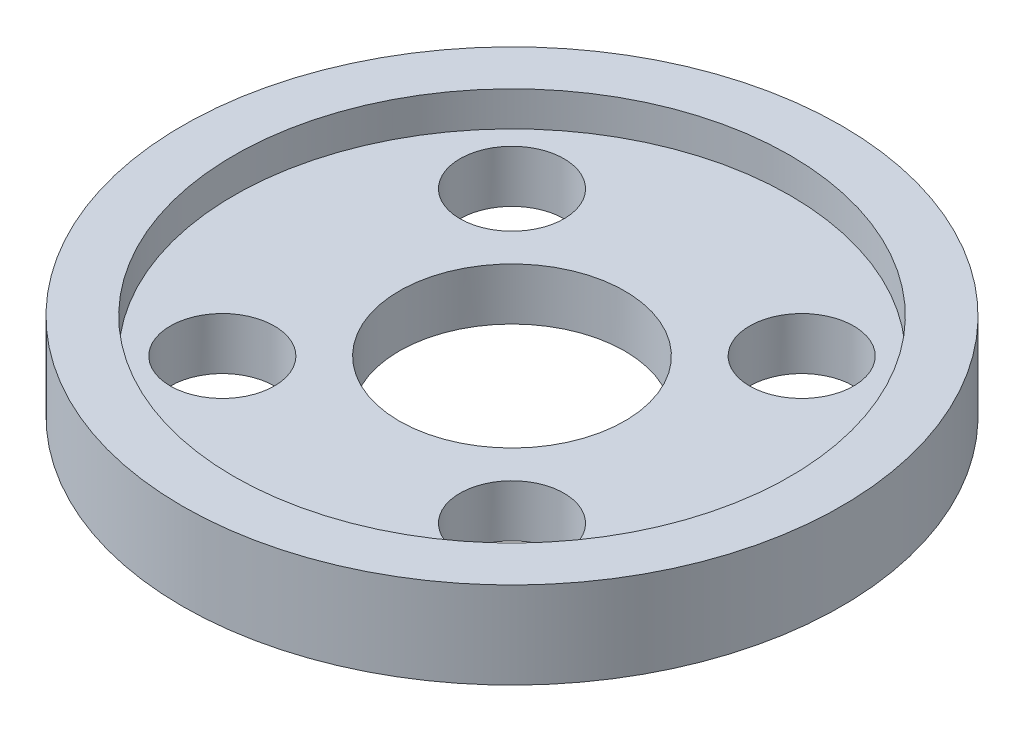
from build123d import *

# Parameters (mm, degrees)
SKETCH1_R           = 105
BOSS_EXTRUDE1_DEPTH = 40
SKETCH3_R           = 6.5
CUT_EXTRUDE2_DEPTH  = 40
SKETCH4_R           = 16.035
CUT_EXTRUDE3_DEPTH  = 5
SKETCH8_R           = 3
CUT_EXTRUDE6_DEPTH  = 44.5
SKETCH11_R          = 90
SKETCH11_R_2        = 26.035
CUT_EXTRUDE8_DEPTH  = 10
BOSS_EXTRUDE2_START = -3
SKETCH12_R          = 108
SKETCH12_R_2        = 105
BOSS_EXTRUDE2_DEPTH = 3
SKETCH13_R          = 108
SKETCH13_R_2        = 19
CUT_EXTRUDE9_DEPTH  = 158.886034848
SKETCH14_R          = 27.444507403
CUT_EXTRUDE10_DEPTH = 32
SKETCH15_R          = 19
CUT_EXTRUDE11_DEPTH = 3


with BuildPart() as part:
    # Sketch1 → Boss-Extrude1 (new body)
    with BuildSketch(Plane(origin=(0, 0, 0), x_dir=(1, 0, 0), z_dir=(0, 1, 0))):
        Circle(SKETCH1_R)
    extrude(amount=BOSS_EXTRUDE1_DEPTH)

    # Sketch3 → Cut-Extrude2 (cut)
    with BuildSketch(Plane(origin=(0, 40, 0), x_dir=(1, 0, 0), z_dir=(0, 1, 0))):
        Circle(SKETCH3_R)
    extrude(amount=-CUT_EXTRUDE2_DEPTH, mode=Mode.SUBTRACT)

    # Sketch4 → Cut-Extrude3 (cut)
    with BuildSketch(Plane(origin=(0, 40, 0), x_dir=(1, 0, 0), z_dir=(0, 1, 0))):
        Circle(SKETCH4_R)
    extrude(amount=-CUT_EXTRUDE3_DEPTH, mode=Mode.SUBTRACT)

    # Sketch8 → Cut-Extrude6 (cut)
    with BuildSketch(Plane(origin=(0, 35, 0), x_dir=(1, 0, 0), z_dir=(0, 1, 0))):
        with Locations((-8.35, 8.35)):
            Circle(SKETCH8_R)
        with Locations((8.35, 8.35)):
            Circle(SKETCH8_R)
        with Locations((8.35, -8.35)):
            Circle(SKETCH8_R)
        with Locations((-8.35, -8.35)):
            Circle(SKETCH8_R)
    extrude(amount=-CUT_EXTRUDE6_DEPTH, mode=Mode.SUBTRACT)

    # Sketch11 → Cut-Extrude8 (cut)
    with BuildSketch(Plane(origin=(0, 40, 0), x_dir=(1, 0, 0), z_dir=(0, 1, 0))):
        Circle(SKETCH11_R)
        Circle(SKETCH11_R_2, mode=Mode.SUBTRACT)
    extrude(amount=-CUT_EXTRUDE8_DEPTH, mode=Mode.SUBTRACT)

    # Sketch12 → Boss-Extrude2 (add)
    with BuildSketch(Plane(origin=(0, 40, 0), x_dir=(1, 0, 0), z_dir=(0, 1, 0)).offset(BOSS_EXTRUDE2_START)):
        Circle(SKETCH12_R)
        Circle(SKETCH12_R_2, mode=Mode.SUBTRACT)
    boss_extrude2 = extrude(amount=BOSS_EXTRUDE2_DEPTH)

    # Mirror1: Boss-Extrude2 across plane
    add(boss_extrude2.mirror(Plane(origin=(0, 20, 0), x_dir=(0, 0, 1), z_dir=(0, -1, 0))))

    # Sketch13 → Cut-Extrude9 (cut, through all)
    with BuildSketch(Plane(origin=(0, 40, 0), x_dir=(1, 0, 0), z_dir=(0, 1, 0))):
        Circle(SKETCH13_R)
        Circle(SKETCH13_R_2, mode=Mode.SUBTRACT)
    extrude(amount=-CUT_EXTRUDE9_DEPTH, mode=Mode.SUBTRACT)

    # Sketch14 → Cut-Extrude10 (cut)
    with BuildSketch(Plane.XZ):
        Circle(SKETCH14_R)
    extrude(amount=-CUT_EXTRUDE10_DEPTH, mode=Mode.SUBTRACT)

    # Sketch15 → Cut-Extrude11 (cut)
    with BuildSketch(Plane(origin=(0, 40, 0), x_dir=(1, 0, 0), z_dir=(0, 1, 0))):
        Circle(SKETCH15_R)
    extrude(amount=-CUT_EXTRUDE11_DEPTH, mode=Mode.SUBTRACT)


solid = part.part
